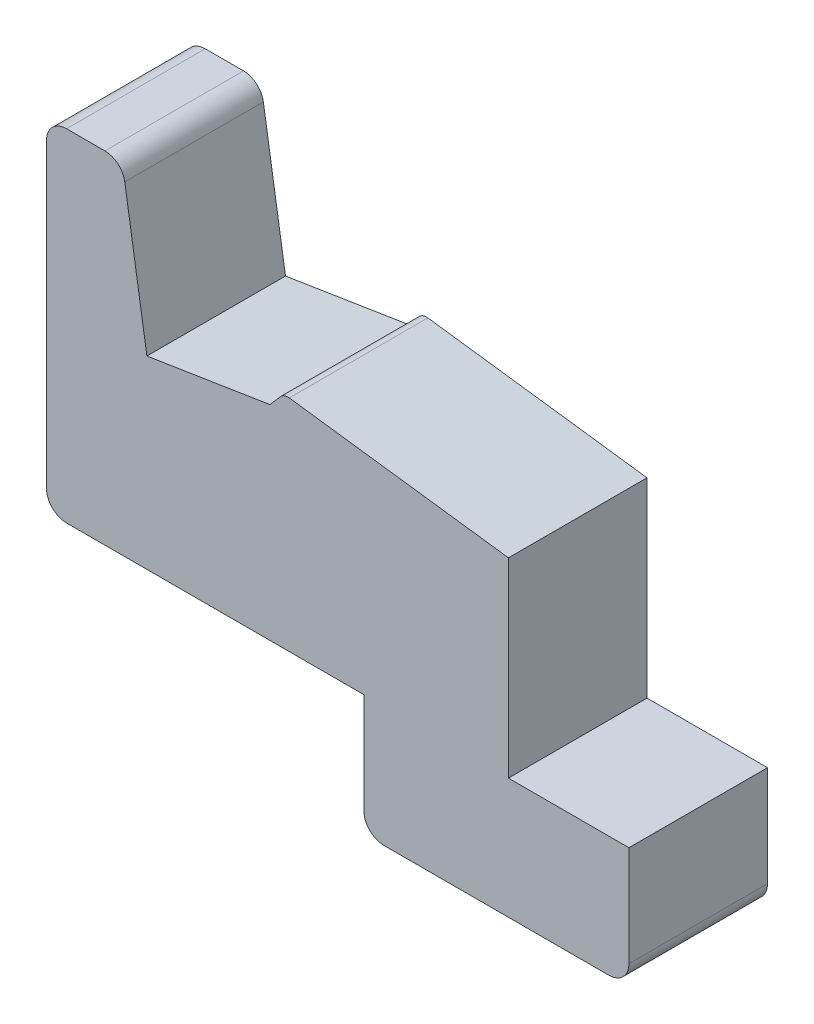
from build123d import *

# Parameters (mm, degrees)
SKETCH1_W               = 23
SKETCH1_H               = 17
BOSS_EXTRUDE1_DEPTH     = 6.9
SKETCH2_W               = 13.2
SKETCH2_H               = 6
BOSS_EXTRUDE2_DEPTH     = 6.9
CUT_EXTRUDE1_DEPTH      = 1
CUT_EXTRUDE1_DEPTH_BACK = 7.9
FILLET1_R               = 0.5
FILLET2_R               = 1


with BuildPart() as part:
    # Sketch1 → Boss-Extrude1 (new body)
    with BuildSketch(Plane.XY):
        Rectangle(SKETCH1_W, SKETCH1_H)
    extrude(amount=BOSS_EXTRUDE1_DEPTH)

    # Sketch2 → Boss-Extrude2 (add)
    with BuildSketch(Plane.XY.offset(6.9)):
        with Locations((10.9, -11.5)):
            Rectangle(SKETCH2_W, SKETCH2_H)
    extrude(amount=-BOSS_EXTRUDE2_DEPTH)

    # Sketch3 → Cut-Extrude1 (cut, two sides)
    with BuildSketch(Plane.XY.offset(6.9)) as cut_extrude1_sk:
        Polygon((90.544433167, -9.417234713), (11.5, 1), (0.321930689, 2.473153352), (-0.376332288, 1.669893683), (-6.5, 0.7), (-7.87864128, 9.404398471), (-20.350835761, 88.150735266), (84.978052457, 207.867025226), (195.873321385, 110.299055247), align=None)
    extrude(amount=CUT_EXTRUDE1_DEPTH, mode=Mode.SUBTRACT)
    extrude(cut_extrude1_sk.sketch, amount=-CUT_EXTRUDE1_DEPTH_BACK, mode=Mode.SUBTRACT)

    # Fillet1
    fillet1_edges = [part.edges().sort_by_distance(p)[0] for p in [
        (0.321930689, 2.473153352, 3.45),
    ]]
    fillet(fillet1_edges, radius=FILLET1_R)

    # Fillet2
    fillet2_edges = [part.edges().sort_by_distance(p)[0] for p in [
        (17.5, -14.5, 3.45),
        (4.3, -14.5, 3.45),
        (-11.5, -8.5, 3.45),
        (-7.735398635, 8.5, 3.45),
        (-11.5, 8.5, 3.45),
    ]]
    fillet(fillet2_edges, radius=FILLET2_R)


solid = part.part
